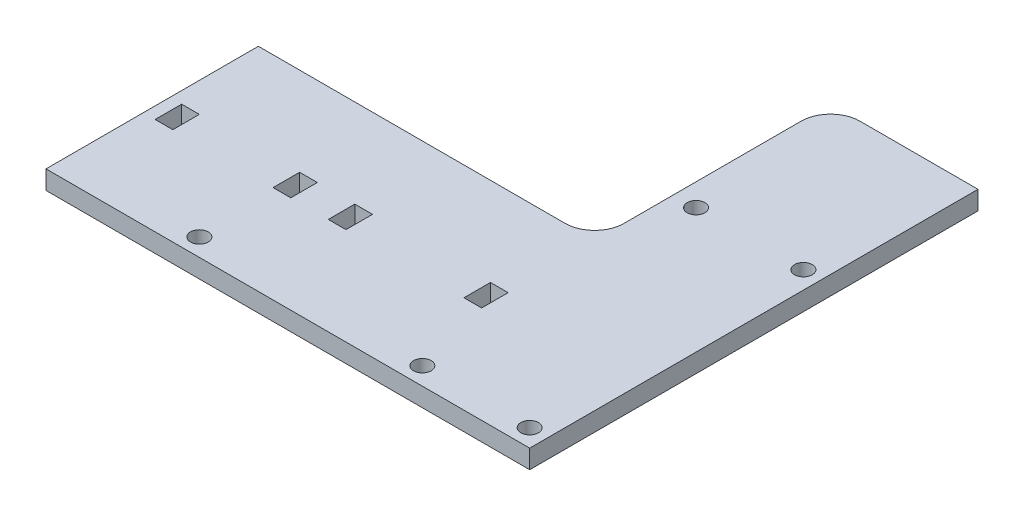
from build123d import *

# Parameters (mm, degrees)
SKETCH1_W           = 25
SKETCH1_H           = 40
SKETCH1_W_2         = 82
SKETCH1_H_2         = 36
BOSS_EXTRUDE1_DEPTH = 3.175
CUT_EXTRUDE1_REACH  = 5.175
SKETCH2_R           = 1.5
SKETCH2_W           = 3
SKETCH2_H           = 4.5
FILLET1_R           = 5


with BuildPart() as part:
    # Sketch1 → Boss-Extrude1 (new body)
    with BuildSketch(Plane(origin=(0, 0, 0), x_dir=(1, 0, 0), z_dir=(0, 1, 0))):
        with Locations((69.5, 20)):
            Rectangle(SKETCH1_W, SKETCH1_H)
        with Locations((41, -18)):
            Rectangle(SKETCH1_W_2, SKETCH1_H_2)
    extrude(amount=BOSS_EXTRUDE1_DEPTH)

    # Sketch2 → Cut-Extrude1 (cut, up to next)
    with BuildSketch(Plane(origin=(0, 3.175, 0), x_dir=(1, 0, 0), z_dir=(0, 1, 0)), mode=Mode.PRIVATE) as cut_extrude1_sk1:
        with Locations((79, -33)):
            Circle(SKETCH2_R)
    cut_extrude1_tool1 = extrude(cut_extrude1_sk1.sketch, amount=-CUT_EXTRUDE1_REACH, mode=Mode.PRIVATE) & part.part
    add(cut_extrude1_tool1.solids().sort_by_distance((79, 3.175, 33))[0], mode=Mode.SUBTRACT)
    # Sketch2 → Cut-Extrude1 (cut, up to next)
    with BuildSketch(Plane(origin=(0, 3.175, 0), x_dir=(1, 0, 0), z_dir=(0, 1, 0)), mode=Mode.PRIVATE) as cut_extrude1_sk2:
        with Locations((60.8, -33)):
            Circle(SKETCH2_R)
    cut_extrude1_tool2 = extrude(cut_extrude1_sk2.sketch, amount=-CUT_EXTRUDE1_REACH, mode=Mode.PRIVATE) & part.part
    add(cut_extrude1_tool2.solids().sort_by_distance((60.8, 3.175, 33))[0], mode=Mode.SUBTRACT)
    # Sketch2 → Cut-Extrude1 (cut, up to next)
    with BuildSketch(Plane(origin=(0, 3.175, 0), x_dir=(1, 0, 0), z_dir=(0, 1, 0)), mode=Mode.PRIVATE) as cut_extrude1_sk3:
        with Locations((60.8, 13.4)):
            Circle(SKETCH2_R)
    cut_extrude1_tool3 = extrude(cut_extrude1_sk3.sketch, amount=-CUT_EXTRUDE1_REACH, mode=Mode.PRIVATE) & part.part
    add(cut_extrude1_tool3.solids().sort_by_distance((60.8, 3.175, -13.4))[0], mode=Mode.SUBTRACT)
    # Sketch2 → Cut-Extrude1 (cut, up to next)
    with BuildSketch(Plane(origin=(0, 3.175, 0), x_dir=(1, 0, 0), z_dir=(0, 1, 0)), mode=Mode.PRIVATE) as cut_extrude1_sk4:
        with Locations((79, 13.4)):
            Circle(SKETCH2_R)
    cut_extrude1_tool4 = extrude(cut_extrude1_sk4.sketch, amount=-CUT_EXTRUDE1_REACH, mode=Mode.PRIVATE) & part.part
    add(cut_extrude1_tool4.solids().sort_by_distance((79, 3.175, -13.4))[0], mode=Mode.SUBTRACT)
    # Sketch2 → Cut-Extrude1 (cut, up to next)
    with BuildSketch(Plane(origin=(0, 3.175, 0), x_dir=(1, 0, 0), z_dir=(0, 1, 0)), mode=Mode.PRIVATE) as cut_extrude1_sk5:
        with Locations((23, -33)):
            Circle(SKETCH2_R)
    cut_extrude1_tool5 = extrude(cut_extrude1_sk5.sketch, amount=-CUT_EXTRUDE1_REACH, mode=Mode.PRIVATE) & part.part
    add(cut_extrude1_tool5.solids().sort_by_distance((23, 3.175, 33))[0], mode=Mode.SUBTRACT)
    # Sketch2 → Cut-Extrude1 (cut, up to next)
    with BuildSketch(Plane(origin=(0, 3.175, 0), x_dir=(1, 0, 0), z_dir=(0, 1, 0)), mode=Mode.PRIVATE) as cut_extrude1_sk6:
        with Locations((32.85, -17.25)):
            Rectangle(SKETCH2_W, SKETCH2_H)
    cut_extrude1_tool6 = extrude(cut_extrude1_sk6.sketch, amount=-CUT_EXTRUDE1_REACH, mode=Mode.PRIVATE) & part.part
    add(cut_extrude1_tool6.solids().sort_by_distance((32.85, 3.175, 17.25))[0], mode=Mode.SUBTRACT)
    # Sketch2 → Cut-Extrude1 (cut, up to next)
    with BuildSketch(Plane(origin=(0, 3.175, 0), x_dir=(1, 0, 0), z_dir=(0, 1, 0)), mode=Mode.PRIVATE) as cut_extrude1_sk7:
        with Locations((55.85, -17.25)):
            Rectangle(SKETCH2_W, SKETCH2_H)
    cut_extrude1_tool7 = extrude(cut_extrude1_sk7.sketch, amount=-CUT_EXTRUDE1_REACH, mode=Mode.PRIVATE) & part.part
    add(cut_extrude1_tool7.solids().sort_by_distance((55.85, 3.175, 17.25))[0], mode=Mode.SUBTRACT)
    # Sketch2 → Cut-Extrude1 (cut, up to next)
    with BuildSketch(Plane(origin=(0, 3.175, 0), x_dir=(1, 0, 0), z_dir=(0, 1, 0)), mode=Mode.PRIVATE) as cut_extrude1_sk8:
        with Locations((3.5, -17.25)):
            Rectangle(SKETCH2_W, SKETCH2_H)
    cut_extrude1_tool8 = extrude(cut_extrude1_sk8.sketch, amount=-CUT_EXTRUDE1_REACH, mode=Mode.PRIVATE) & part.part
    add(cut_extrude1_tool8.solids().sort_by_distance((3.5, 3.175, 17.25))[0], mode=Mode.SUBTRACT)
    # Sketch2 → Cut-Extrude1 (cut, up to next)
    with BuildSketch(Plane(origin=(0, 3.175, 0), x_dir=(1, 0, 0), z_dir=(0, 1, 0)), mode=Mode.PRIVATE) as cut_extrude1_sk9:
        with Locations((23.5, -17.25)):
            Rectangle(SKETCH2_W, SKETCH2_H)
    cut_extrude1_tool9 = extrude(cut_extrude1_sk9.sketch, amount=-CUT_EXTRUDE1_REACH, mode=Mode.PRIVATE) & part.part
    add(cut_extrude1_tool9.solids().sort_by_distance((23.5, 3.175, 17.25))[0], mode=Mode.SUBTRACT)

    # Fillet1
    fillet1_edges = [part.edges().sort_by_distance(p)[0] for p in [
        (57, 1.5875, -40),
        (57, 1.5875, 0),
    ]]
    fillet(fillet1_edges, radius=FILLET1_R)


solid = part.part
